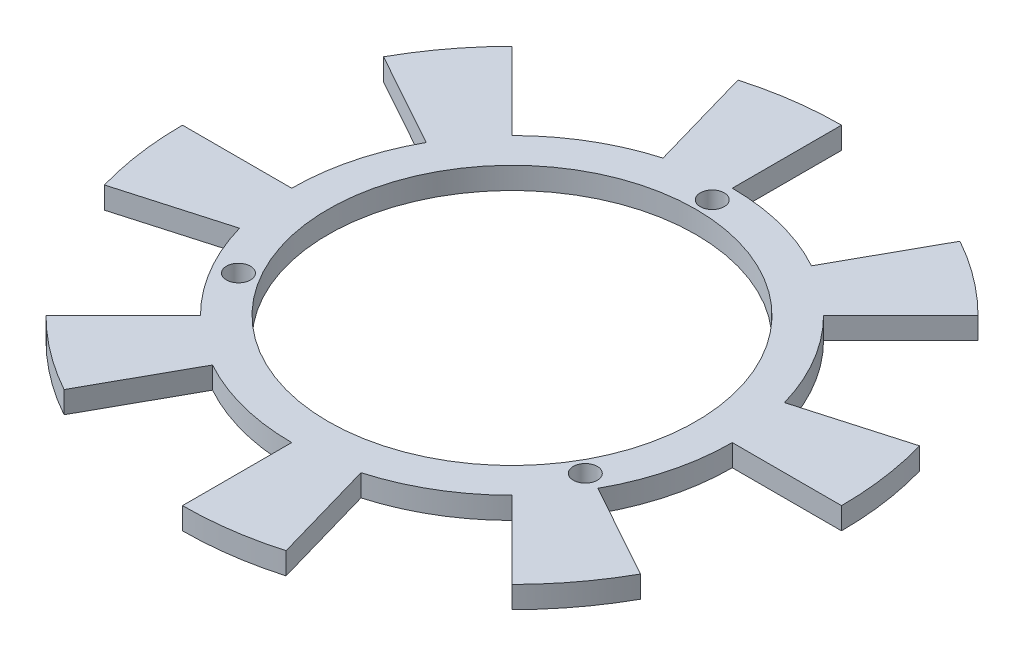
from build123d import *

# Parameters (mm, degrees)
SKETCH1_R           = 30.25
SKETCH1_R_2         = 25.25
EXTRUDE_THIN1_DEPTH = 3
SKETCH2_R           = 1.65
CUT_EXTRUDE3_DEPTH  = 10
BOSS_EXTRUDE1_DEPTH = 3


with BuildPart() as part:
    # Sketch1 → Extrude-Thin1 (new body)
    with BuildSketch(Plane(origin=(0, 0, 0), x_dir=(1, 0, 0), z_dir=(0, 1, 0))):
        Circle(SKETCH1_R)
        Circle(SKETCH1_R_2, mode=Mode.SUBTRACT)
    extrude(amount=-EXTRUDE_THIN1_DEPTH)

    # Sketch2 → Cut-Extrude3 (cut)
    with BuildSketch(Plane(origin=(0, 0, 0), x_dir=(1, 0, 0), z_dir=(0, 1, 0))):
        with Locations((0, 27.5)):
            Circle(SKETCH2_R)
        with Locations((23.815698604, -13.75)):
            Circle(SKETCH2_R)
        with Locations((-23.815698604, -13.75)):
            Circle(SKETCH2_R)
    extrude(amount=-CUT_EXTRUDE3_DEPTH, mode=Mode.SUBTRACT)

    # Sketch5 → Boss-Extrude1 (add)
    with BuildSketch(Plane.XZ.offset(3)):
        with BuildLine():
            Line((0, 45.25), (0, 30.25))
            ThreePointArc((0, 30.25), (4.209986304, 29.955609079), (8.338030013, 29.078166302))
            Line((8.338030013, 29.078166302), (12.472590351, 43.497091741))
            ThreePointArc((12.472590351, 43.497091741), (6.297582818, 44.809630111), (0, 45.25))
        make_face()
        with BuildLine():
            Line((31.996581849, 31.996581849), (21.389980131, 21.389980131))
            ThreePointArc((21.389980131, 21.389980131), (24.158724179, 18.20490445), (26.457246141, 14.665491012))
            Line((26.457246141, 14.665491012), (39.576541748, 21.937635316))
            ThreePointArc((39.576541748, 21.937635316), (36.13825683, 27.232129798), (31.996581849, 31.996581849))
        make_face()
        with BuildLine():
            Line((45.25, 0), (30.25, 0))
            ThreePointArc((30.25, 0), (29.955609079, -4.209986304), (29.078166302, -8.338030013))
            Line((29.078166302, -8.338030013), (43.497091741, -12.472590351))
            ThreePointArc((43.497091741, -12.472590351), (44.809630111, -6.297582818), (45.25, 0))
        make_face()
        with BuildLine():
            Line((31.996581849, -31.996581849), (21.389980131, -21.389980131))
            ThreePointArc((21.389980131, -21.389980131), (18.20490445, -24.158724179), (14.665491012, -26.457246141))
            Line((14.665491012, -26.457246141), (21.937635316, -39.576541748))
            ThreePointArc((21.937635316, -39.576541748), (27.232129798, -36.13825683), (31.996581849, -31.996581849))
        make_face()
        with BuildLine():
            Line((0, -45.25), (0, -30.25))
            ThreePointArc((0, -30.25), (-4.209986304, -29.955609079), (-8.338030013, -29.078166302))
            Line((-8.338030013, -29.078166302), (-12.472590351, -43.497091741))
            ThreePointArc((-12.472590351, -43.497091741), (-6.297582818, -44.809630111), (0, -45.25))
        make_face()
        with BuildLine():
            Line((-31.996581849, -31.996581849), (-21.389980131, -21.389980131))
            ThreePointArc((-21.389980131, -21.389980131), (-24.158724179, -18.20490445), (-26.457246141, -14.665491012))
            Line((-26.457246141, -14.665491012), (-39.576541748, -21.937635316))
            ThreePointArc((-39.576541748, -21.937635316), (-36.13825683, -27.232129798), (-31.996581849, -31.996581849))
        make_face()
        with BuildLine():
            Line((-45.25, 0), (-30.25, 0))
            ThreePointArc((-30.25, 0), (-29.955609079, 4.209986304), (-29.078166302, 8.338030013))
            Line((-29.078166302, 8.338030013), (-43.497091741, 12.472590351))
            ThreePointArc((-43.497091741, 12.472590351), (-44.809630111, 6.297582818), (-45.25, 0))
        make_face()
        with BuildLine():
            Line((-31.996581849, 31.996581849), (-21.389980131, 21.389980131))
            ThreePointArc((-21.389980131, 21.389980131), (-18.20490445, 24.158724179), (-14.665491012, 26.457246141))
            Line((-14.665491012, 26.457246141), (-21.937635316, 39.576541748))
            ThreePointArc((-21.937635316, 39.576541748), (-27.232129798, 36.13825683), (-31.996581849, 31.996581849))
        make_face()
    extrude(amount=-BOSS_EXTRUDE1_DEPTH)


solid = part.part
